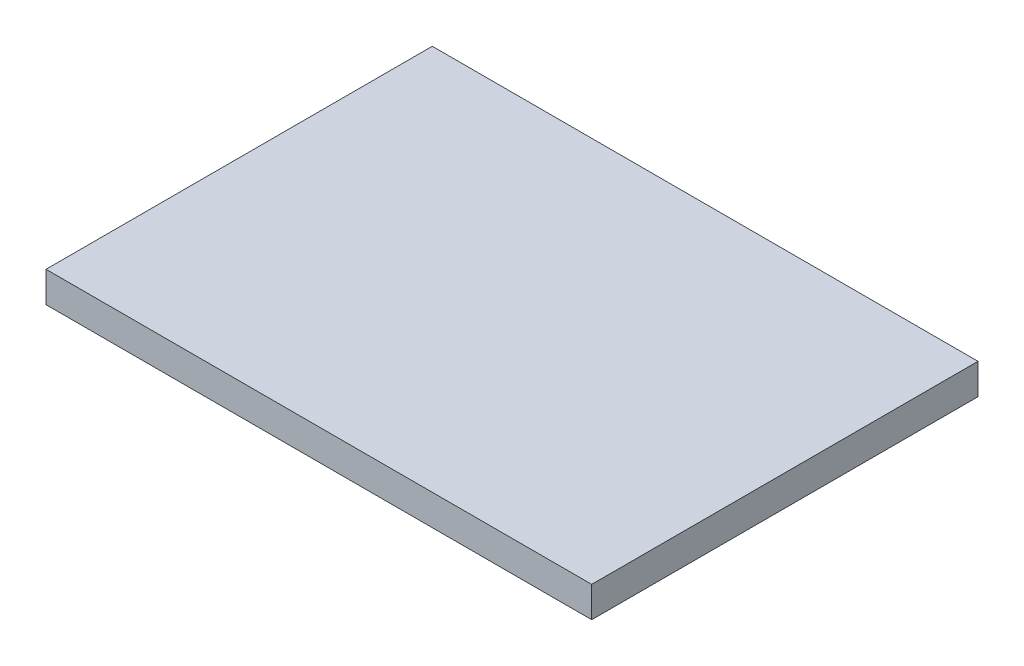
from build123d import *

# Parameters (mm, degrees)
SKETCH1_W           = 35.6
SKETCH1_H           = 25.2
BOSS_EXTRUDE1_DEPTH = 2


with BuildPart() as part:
    # Sketch1 → Boss-Extrude1 (new body)
    with BuildSketch(Plane(origin=(0, 0, 0), x_dir=(1, 0, 0), z_dir=(0, 1, 0))):
        Rectangle(SKETCH1_W, SKETCH1_H)
    extrude(amount=BOSS_EXTRUDE1_DEPTH)


solid = part.part
